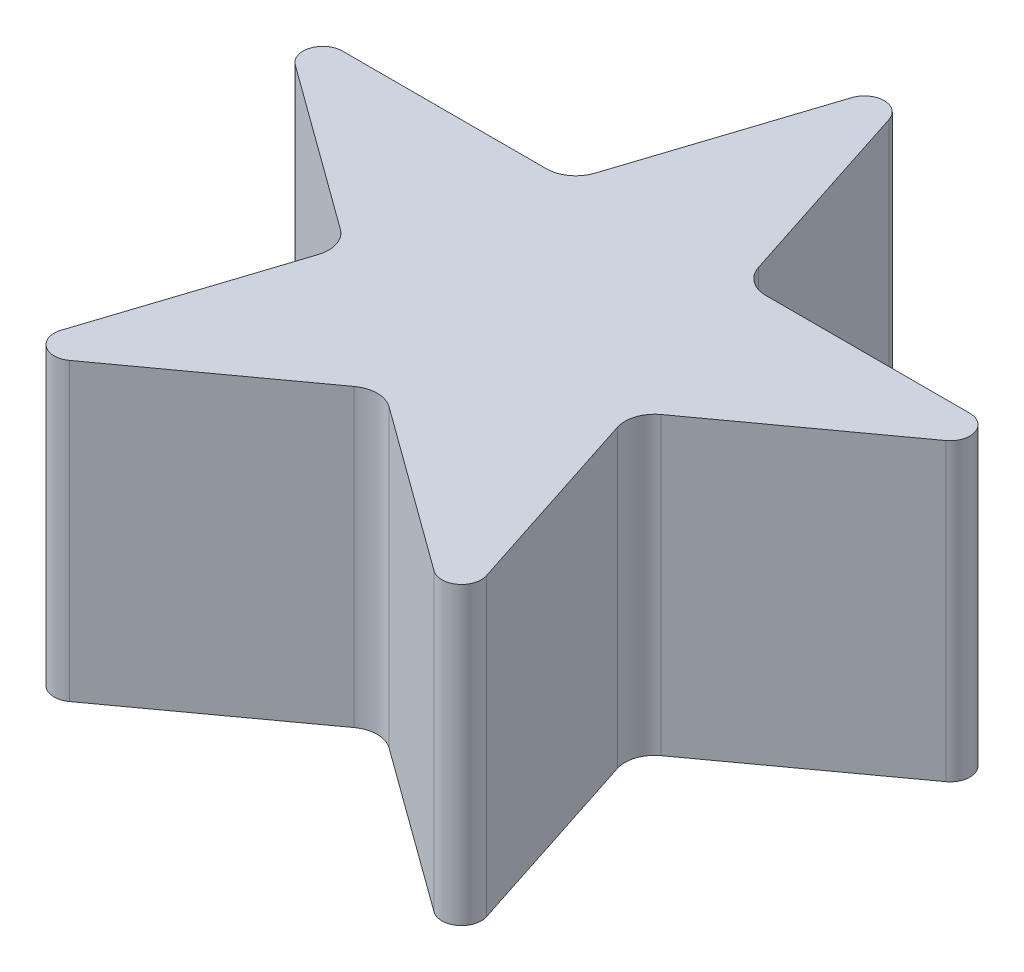
from build123d import *

# Parameters (mm, degrees)
BOSS_EXTRUDE1_DEPTH = 30
FILLET1_R           = 2
FILLET2_R           = 3


with BuildPart() as part:
    # Sketch2 → Boss-Extrude1 (new body)
    with BuildSketch(Plane(origin=(0, 0, 0), x_dir=(1, 0, 0), z_dir=(0, 1, 0))):
        Polygon((0, 39.962281052), (-8.9720911, 12.349023979), (-38.0063878, 12.349023979), (-14.51714835, -4.716907432), (-23.48923945, -32.330164505), (0, -15.264233094), (23.48923945, -32.330164505), (14.51714835, -4.716907432), (38.0063878, 12.349023979), (8.9720911, 12.349023979), align=None)
    extrude(amount=BOSS_EXTRUDE1_DEPTH)

    # Fillet1
    fillet1_edges = [part.edges().sort_by_distance(p)[0] for p in [
        (23.48923945, 15, 32.330164505),
        (-23.48923945, 15, 32.330164505),
        (-38.0063878, 15, -12.349023979),
        (0, 15, -39.962281052),
        (38.0063878, 15, -12.349023979),
    ]]
    fillet(fillet1_edges, radius=FILLET1_R)

    # Fillet2
    fillet2_edges = [part.edges().sort_by_distance(p)[0] for p in [
        (14.51714835, 15, 4.716907432),
        (0, 15, 15.264233094),
        (-14.51714835, 15, 4.716907432),
        (-8.9720911, 15, -12.349023979),
        (8.9720911, 15, -12.349023979),
    ]]
    fillet(fillet2_edges, radius=FILLET2_R)


solid = part.part
